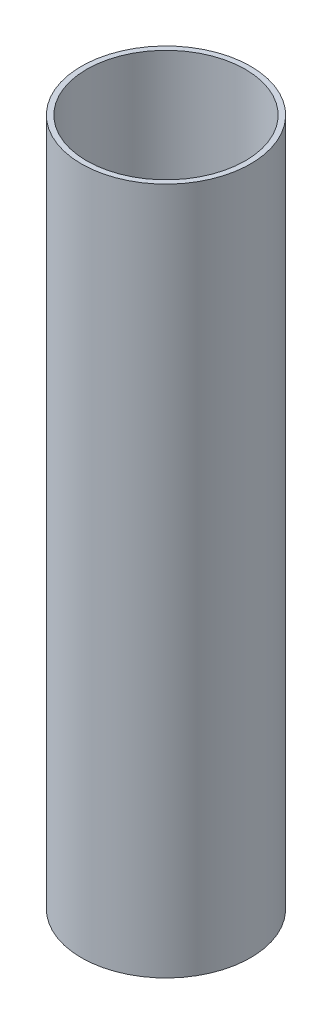
from build123d import *

# Parameters (mm, degrees)
SKETCH_1_R      = 16
SKETCH_1_R_2    = 15
EXTRUDE_1_DEPTH = 130


with BuildPart() as part:
    # 草图1 → 凸台-拉伸1 (new body)
    with BuildSketch(Plane(origin=(0, 0, 0), x_dir=(1, 0, 0), z_dir=(0, 1, 0))):
        Circle(SKETCH_1_R)
        Circle(SKETCH_1_R_2, mode=Mode.SUBTRACT)
    extrude(amount=EXTRUDE_1_DEPTH)


solid = part.part
